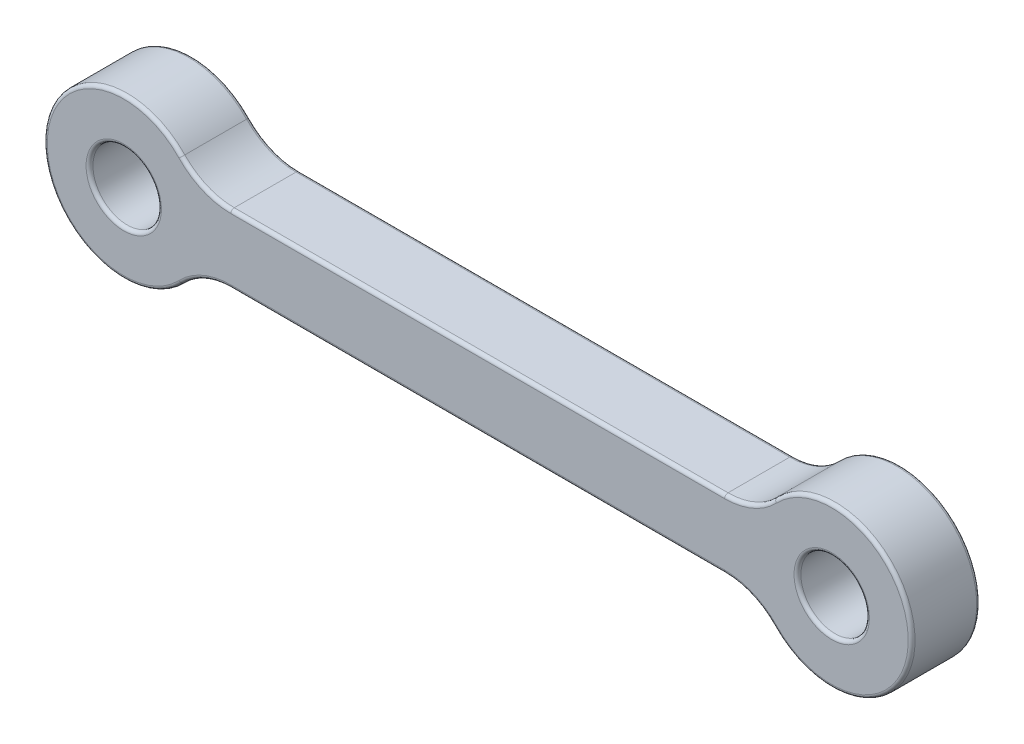
from build123d import *

# Parameters (mm, degrees)
SKETCH1_R           = 3.5
SKETCH1_R_2         = 1.5
BOSS_EXTRUDE1_DEPTH = 1.5
FILLET1_R           = 3
FILLET3_R           = 0.15


with BuildPart() as part:
    # Sketch1 → Boss-Extrude1 (new body, symmetric)
    with BuildSketch(Plane.XY):
        Circle(SKETCH1_R)
        Circle(SKETCH1_R_2, mode=Mode.SUBTRACT)
        with BuildLine():
            Line((3.16227766, -1.5), (27.83772234, -1.5))
            ThreePointArc((27.83772234, -1.5), (27.5, 0), (27.83772234, 1.5))
            Line((27.83772234, 1.5), (3.16227766, 1.5))
            ThreePointArc((3.16227766, 1.5), (3.414525722, 0.768774411), (3.5, 0))
            ThreePointArc((3.5, 0), (3.414525722, -0.768774411), (3.16227766, -1.5))
        make_face()
        with Locations((31, 0)):
            Circle(SKETCH1_R)
        with Locations((31, 0)):
            Circle(SKETCH1_R_2, mode=Mode.SUBTRACT)
    extrude(amount=BOSS_EXTRUDE1_DEPTH, both=True)

    # Fillet1
    fillet1_edges = [part.edges().sort_by_distance(p)[0] for p in [
        (27.83772234, 1.5, 0),
        (27.83772234, -1.5, 0),
        (3.16227766, -1.5, 0),
        (3.16227766, 1.5, 0),
    ]]
    fillet(fillet1_edges, radius=FILLET1_R)

    # Fillet3
    fillet3_edges = [part.edges().sort_by_distance(p)[0] for p in [
        (34.5, 0, -1.5),
        (34.5, 0, 1.5),
        (-1.5, 0, 1.5),
        (15.5, -1.5, -1.5),
        (15.5, -1.5, 1.5),
        (-3.5, 0, -1.5),
        (-3.5, 0, 1.5),
        (29.5, 0, 1.5),
        (15.5, 1.5, -1.5),
        (15.5, 1.5, 1.5),
        (27.486281051, -1.740401367, -1.5),
        (27.486281051, -1.740401367, 1.5),
        (3.513718949, -1.740401367, -1.5),
        (3.513718949, -1.740401367, 1.5),
        (27.486281051, 1.740401367, -1.5),
        (27.486281051, 1.740401367, 1.5),
        (3.513718949, 1.740401367, -1.5),
        (3.513718949, 1.740401367, 1.5),
        (29.5, 0, -1.5),
        (-1.5, 0, -1.5),
    ]]
    fillet(fillet3_edges, radius=FILLET3_R)


solid = part.part
